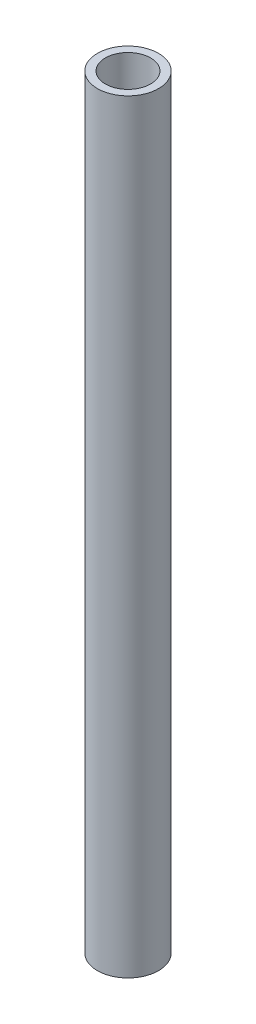
from build123d import *

# Parameters (mm, degrees)
SKETCH1_R           = 10.668
SKETCH1_R_2         = 7.8994
BOSS_EXTRUDE1_DEPTH = 266.7


with BuildPart() as part:
    # Sketch1 → Boss-Extrude1 (new body)
    with BuildSketch(Plane(origin=(0, 0, 0), x_dir=(1, 0, 0), z_dir=(0, 1, 0))):
        Circle(SKETCH1_R)
        Circle(SKETCH1_R_2, mode=Mode.SUBTRACT)
    extrude(amount=BOSS_EXTRUDE1_DEPTH)


solid = part.part
